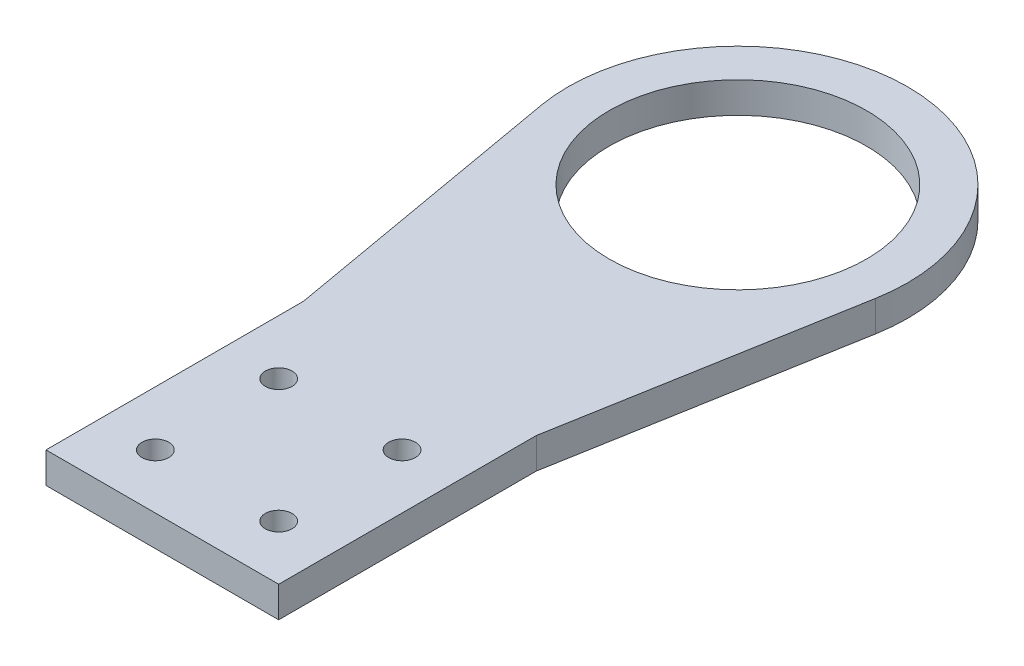
from build123d import *

# Parameters (mm, degrees)
SKETCH1_R           = 39.751
SKETCH1_R_2         = 4.1275
BOSS_EXTRUDE1_DEPTH = 9.525


with BuildPart() as part:
    # Sketch1 → Boss-Extrude1 (new body)
    with BuildSketch(Plane(origin=(0, 0, 0), x_dir=(1, 0, 0), z_dir=(0, 1, 0))):
        with BuildLine():
            Line((-35.941, 0), (35.941, 0))
            Line((35.941, 0), (35.941, 79.578269268))
            Line((35.941, 79.578269268), (51.654151453, 168.691979433))
            ThreePointArc((51.654151453, 168.691979433), (0, 230.251), (-51.654151453, 168.691979433))
            Line((-51.654151453, 168.691979433), (-35.941, 79.578269268))
            Line((-35.941, 79.578269268), (-35.941, 0))
        make_face()
        with Locations((0, 177.8)):
            Circle(SKETCH1_R, mode=Mode.SUBTRACT)
        with Locations((-19.05, 54.991)):
            Circle(SKETCH1_R_2, mode=Mode.SUBTRACT)
        with Locations((19.05, 54.991)):
            Circle(SKETCH1_R_2, mode=Mode.SUBTRACT)
        with Locations((19.05, 16.891)):
            Circle(SKETCH1_R_2, mode=Mode.SUBTRACT)
        with Locations((-19.05, 16.891)):
            Circle(SKETCH1_R_2, mode=Mode.SUBTRACT)
    extrude(amount=BOSS_EXTRUDE1_DEPTH)


solid = part.part
